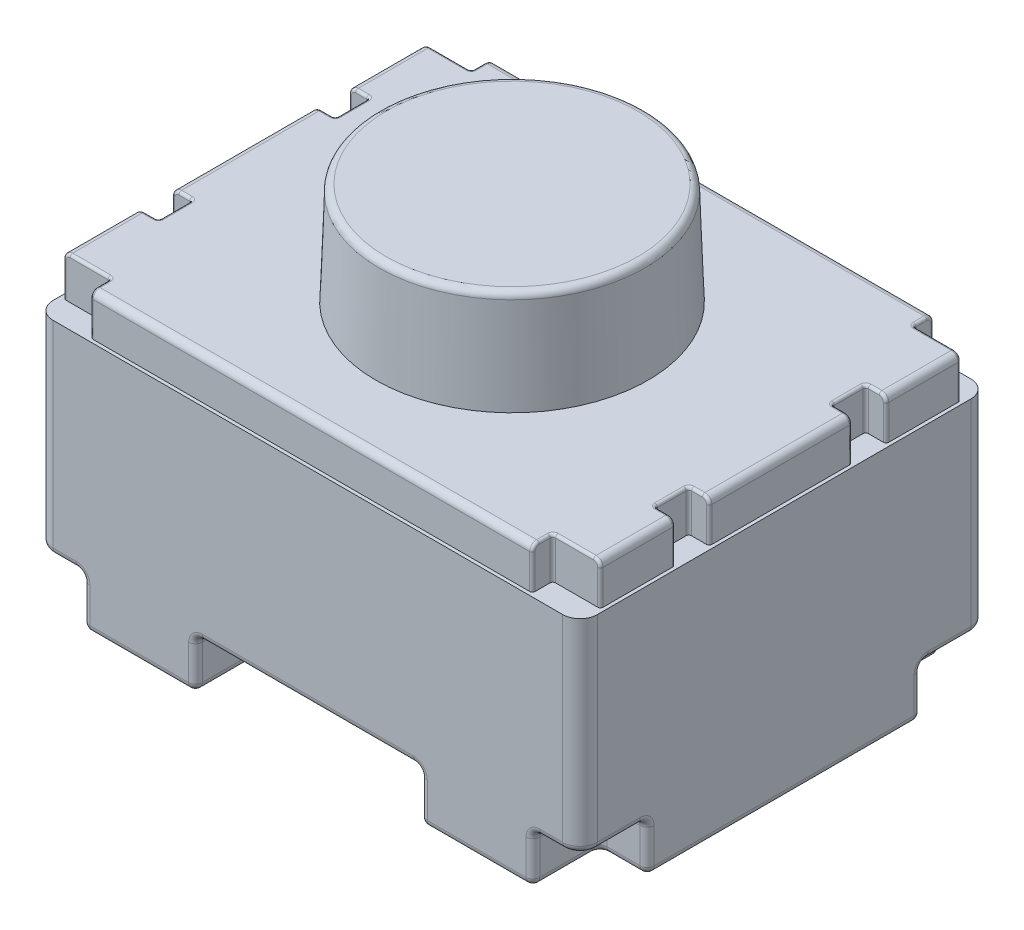
from build123d import *

# Parameters (mm, degrees)
BOSS_EXTRUDE1_START = 0.5588
SKETCH1_W           = 4
SKETCH1_H           = 3
BOSS_EXTRUDE1_DEPTH = 1.5
FILLET1_R           = 0.127
BOSS_EXTRUDE2_DEPTH = 0.3048
BOSS_EXTRUDE3_REACH = 4.564
BOSS_EXTRUDE3_START = 0.2
SKETCH5_R           = 1
BOSS_EXTRUDE5_DEPTH = 0.75
BOSS_EXTRUDE5_TAPER = 2
FILLET3_R           = 0.0508
SKETCH6_W           = 0.15
SKETCH6_H           = 0.25
CUT_EXTRUDE1_DEPTH  = 0.3048
FILLET4_R           = 0.02
FILLET5_R           = 0.05


with BuildPart() as part:
    # Sketch1 → Boss-Extrude1 (new body)
    with BuildSketch(Plane(origin=(0, 0, 0), x_dir=(1, 0, 0), z_dir=(0, 1, 0)).offset(BOSS_EXTRUDE1_START)):
        Rectangle(SKETCH1_W, SKETCH1_H)
    extrude(amount=BOSS_EXTRUDE1_DEPTH)

    # Fillet1
    fillet1_edges = [part.edges().sort_by_distance(p)[0] for p in [
        (2, 1.3088, 1.5),
        (-2, 1.3088, 1.5),
        (-2, 1.3088, -1.5),
        (2, 1.3088, -1.5),
    ]]
    fillet(fillet1_edges, radius=FILLET1_R)

    # Sketch2 → Boss-Extrude2 (add)
    with BuildSketch(Plane(origin=(0, 2.0588, 0), x_dir=(-1, 0, 0), z_dir=(0, -1, 0))):
        with BuildLine():
            Line((1.9746, -1.373), (1.9746, 1.373))
            ThreePointArc((1.9746, 1.373), (1.944842049, 1.444842049), (1.873, 1.4746))
            Line((1.873, 1.4746), (-1.873, 1.4746))
            ThreePointArc((-1.873, 1.4746), (-1.944842049, 1.444842049), (-1.9746, 1.373))
            Line((-1.9746, 1.373), (-1.9746, -1.373))
            ThreePointArc((-1.9746, -1.373), (-1.944842049, -1.444842049), (-1.873, -1.4746))
            Line((-1.873, -1.4746), (1.873, -1.4746))
            ThreePointArc((1.873, -1.4746), (1.944842049, -1.444842049), (1.9746, -1.373))
        make_face()
    extrude(amount=-BOSS_EXTRUDE2_DEPTH)

    # Sketch3 → Boss-Extrude3 (add, up to next)
    with BuildSketch(Plane(origin=(0, 0, 0), x_dir=(1, 0, 0), z_dir=(0, 1, 0)).offset(BOSS_EXTRUDE3_START), mode=Mode.PRIVATE) as boss_extrude3_sk1:
        Polygon((-1.65323541, -1.5), (-1.65323541, -1.006902093), (-2, -1.006902093), (-2, 1.006902093), (-1.65323541, 1.006902093), (-1.65323541, 1.5), (-0.826439501, 1.5), (-0.826439501, 0.473804959), (-1.582835796, 0.473804959), (-1.582835796, -0.473804959), (-0.826439501, -0.473804959), (-0.826439501, -1.5), align=None)
    boss_extrude3_tool1 = extrude(boss_extrude3_sk1.sketch, amount=BOSS_EXTRUDE3_REACH, mode=Mode.PRIVATE) - part.part
    add(boss_extrude3_tool1.solids().sort_by_distance((-1.621022, 0.2, 1.253451))[0])
    # Sketch3 → Boss-Extrude3 (add, up to next)
    with BuildSketch(Plane(origin=(0, 0, 0), x_dir=(1, 0, 0), z_dir=(0, 1, 0)).offset(BOSS_EXTRUDE3_START), mode=Mode.PRIVATE) as boss_extrude3_sk2:
        Polygon((1.65323541, 1.5), (1.65323541, 1.006902093), (2, 1.006902093), (2, -1.006902093), (1.65323541, -1.006902093), (1.65323541, -1.5), (0.826439501, -1.5), (0.826439501, -0.473804959), (1.582835796, -0.473804959), (1.582835796, 0.473804959), (0.826439501, 0.473804959), (0.826439501, 1.5), align=None)
    boss_extrude3_tool2 = extrude(boss_extrude3_sk2.sketch, amount=BOSS_EXTRUDE3_REACH, mode=Mode.PRIVATE) - part.part
    add(boss_extrude3_tool2.solids().sort_by_distance((1.621022, 0.2, -1.253451))[0])

    # Sketch5 → Boss-Extrude5 (add)
    with BuildSketch(Plane(origin=(0, 2.3636, 0), x_dir=(1, 0, 0), z_dir=(0, 1, 0))):
        Circle(SKETCH5_R)
    extrude(amount=BOSS_EXTRUDE5_DEPTH, taper=BOSS_EXTRUDE5_TAPER)

    # Fillet3
    fillet3_edges = [part.edges().sort_by_distance(p)[0] for p in [
        (0.826439501, 0.5588, -0.98690248),
        (0.826439501, 0.3794, -1.5),
        (0.826439501, 0.2, -0.98690248),
        (1.204637649, 0.5588, -0.473804959),
        (0.826439501, 0.3794, -0.473804959),
        (1.204637649, 0.2, -0.473804959),
        (1.582835796, 0.5588, 0),
        (1.582835796, 0.3794, -0.473804959),
        (1.582835796, 0.2, 0),
        (1.204637649, 0.5588, 0.473804959),
        (1.582835796, 0.3794, 0.473804959),
        (1.204637649, 0.2, 0.473804959),
        (0.826439501, 0.5588, 0.98690248),
        (0.826439501, 0.3794, 0.473804959),
        (0.826439501, 0.2, 0.98690248),
        (0.826439501, 0.3794, 1.5),
        (1.239837456, 0.2, 1.5),
        (1.65323541, 0.5588, 1.253451047),
        (1.65323541, 0.3794, 1.5),
        (1.65323541, 0.2, 1.253451047),
        (1.826617705, 0.5588, 1.006902093),
        (1.65323541, 0.3794, 1.006902093),
        (1.826617705, 0.2, 1.006902093),
        (2, 0.3794, 1.006902093),
        (2, 0.2, 0),
        (1.826617705, 0.5588, -1.006902093),
        (2, 0.3794, -1.006902093),
        (1.826617705, 0.2, -1.006902093),
        (1.65323541, 0.3794, -1.5),
        (1.239837456, 0.2, -1.5),
        (1.65323541, 0.5588, -1.253451047),
        (1.65323541, 0.3794, -1.006902093),
        (1.65323541, 0.2, -1.253451047),
        (-1.763117705, 0.5588, 1.5),
        (2, 0.5588, 1.189951047),
        (-2, 0.5588, -1.189951047),
        (1.763117705, 0.5588, -1.5),
        (1.962802561, 0.5588, 1.462802561),
        (1.962802561, 0.5588, -1.462802561),
        (-1.962802561, 0.5588, -1.462802561),
        (-1.962802561, 0.5588, 1.462802561),
        (-1.944842049, 2.3636, 1.444842049),
        (0, 2.3636, 1.4746),
        (1.944842049, 2.3636, 1.444842049),
        (1.9746, 2.3636, 0),
        (1.944842049, 2.3636, -1.444842049),
        (0, 2.3636, -1.4746),
        (-1.944842049, 2.3636, -1.444842049),
        (-1.9746, 2.3636, 0),
        (0, 0.5588, 1.5),
        (-2, 0.5588, 1.189951047),
        (-1.763117705, 0.5588, -1.5),
        (-0.826439501, 0.5588, 0.98690248),
        (-0.826439501, 0.3794, 1.5),
        (-0.826439501, 0.2, 0.98690248),
        (-1.204637649, 0.5588, 0.473804959),
        (-0.826439501, 0.3794, 0.473804959),
        (-1.204637649, 0.2, 0.473804959),
        (-1.582835796, 0.5588, 0),
        (-1.582835796, 0.3794, 0.473804959),
        (-1.582835796, 0.2, 0),
        (-1.204637649, 0.5588, -0.473804959),
        (-1.582835796, 0.3794, -0.473804959),
        (-1.204637649, 0.2, -0.473804959),
        (-0.826439501, 0.5588, -0.98690248),
        (-0.826439501, 0.3794, -0.473804959),
        (-0.826439501, 0.2, -0.98690248),
        (-0.826439501, 0.3794, -1.5),
        (-1.239837456, 0.2, -1.5),
        (-1.65323541, 0.5588, -1.253451047),
        (-1.65323541, 0.3794, -1.5),
        (-1.65323541, 0.2, -1.253451047),
        (-1.826617705, 0.5588, -1.006902093),
        (-1.65323541, 0.3794, -1.006902093),
        (-1.826617705, 0.2, -1.006902093),
        (-2, 0.3794, -1.006902093),
        (-2, 0.2, 0),
        (-1.826617705, 0.5588, 1.006902093),
        (-2, 0.3794, 1.006902093),
        (-1.826617705, 0.2, 1.006902093),
        (-1.65323541, 0.3794, 1.5),
        (-1.239837456, 0.2, 1.5),
        (-1.65323541, 0.5588, 1.253451047),
        (-1.65323541, 0.3794, 1.006902093),
        (-1.65323541, 0.2, 1.253451047),
        (0, 0.5588, -1.5),
        (2, 0.5588, -1.189951047),
        (1.763117705, 0.5588, 1.5),
    ]]
    fillet(fillet3_edges, radius=FILLET3_R)

    # Sketch6 → Cut-Extrude1 (cut)
    with BuildSketch(Plane(origin=(0, 2.3636, 0), x_dir=(1, 0, 0), z_dir=(0, 1, 0))):
        with Locations((-1.8996, 0.65)):
            Rectangle(SKETCH6_W, SKETCH6_H)
        with BuildLine():
            Line((-1.6246, 1.3246), (-1.9746, 1.3246))
            Line((-1.9746, 1.3246), (-1.9746, 1.373))
            ThreePointArc((-1.9746, 1.373), (-1.944842049, 1.444842049), (-1.873, 1.4746))
            Line((-1.873, 1.4746), (-1.6246, 1.4746))
            Line((-1.6246, 1.4746), (-1.6246, 1.3246))
        make_face()
        with BuildLine():
            Line((1.9746, 1.3246), (1.9746, 1.373))
            ThreePointArc((1.9746, 1.373), (1.944842049, 1.444842049), (1.873, 1.4746))
            Line((1.873, 1.4746), (1.6246, 1.4746))
            Line((1.6246, 1.4746), (1.6246, 1.3246))
            Line((1.6246, 1.3246), (1.9746, 1.3246))
        make_face()
        with Locations((1.8996, 0.65)):
            Rectangle(SKETCH6_W, SKETCH6_H)
        with Locations((1.8996, -0.65)):
            Rectangle(SKETCH6_W, SKETCH6_H)
        with BuildLine():
            Line((1.6246, -1.3246), (1.9746, -1.3246))
            Line((1.9746, -1.3246), (1.9746, -1.373))
            ThreePointArc((1.9746, -1.373), (1.944842049, -1.444842049), (1.873, -1.4746))
            Line((1.873, -1.4746), (1.6246, -1.4746))
            Line((1.6246, -1.4746), (1.6246, -1.3246))
        make_face()
        with BuildLine():
            Line((-1.9746, -1.3246), (-1.9746, -1.373))
            ThreePointArc((-1.9746, -1.373), (-1.944842049, -1.444842049), (-1.873, -1.4746))
            Line((-1.873, -1.4746), (-1.6246, -1.4746))
            Line((-1.6246, -1.4746), (-1.6246, -1.3246))
            Line((-1.6246, -1.3246), (-1.9746, -1.3246))
        make_face()
        with Locations((-1.8996, -0.65)):
            Rectangle(SKETCH6_W, SKETCH6_H)
    extrude(amount=-CUT_EXTRUDE1_DEPTH, mode=Mode.SUBTRACT)

    # Fillet4
    fillet4_edges = [part.edges().sort_by_distance(p)[0] for p in [
        (-1.6246, 2.2112, 1.3246),
        (-1.6246, 2.1858, 1.4746),
        (-1.6246, 2.348721024, 1.459721024),
        (-1.6246, 2.3636, 1.3742),
        (-1.7742, 2.3636, 1.3246),
        (-1.959721024, 2.348721024, 1.3246),
        (-1.9746, 2.1858, 1.3246),
        (-1.9746, 2.1858, 0.525),
        (-1.959721024, 2.348721024, 0.525),
        (-1.8742, 2.3636, 0.525),
        (-1.8246, 2.2112, 0.525),
        (-1.8246, 2.3636, 0.65),
        (-1.8246, 2.2112, 0.775),
        (-1.8742, 2.3636, 0.775),
        (-1.959721024, 2.348721024, 0.775),
        (-1.9746, 2.1858, 0.775),
        (-1.9746, 2.1858, -0.525),
        (-1.959721024, 2.348721024, -0.525),
        (-1.8742, 2.3636, -0.525),
        (-1.8246, 2.2112, -0.525),
        (-1.8246, 2.3636, -0.65),
        (-1.8246, 2.2112, -0.775),
        (-1.8742, 2.3636, -0.775),
        (-1.959721024, 2.348721024, -0.775),
        (-1.9746, 2.1858, -0.775),
        (-1.9746, 2.1858, -1.3246),
        (-1.959721024, 2.348721024, -1.3246),
        (-1.7742, 2.3636, -1.3246),
        (-1.6246, 2.2112, -1.3246),
        (-1.6246, 2.3636, -1.3742),
        (-1.6246, 2.348721024, -1.459721024),
        (-1.6246, 2.1858, -1.4746),
        (1.6246, 2.1858, -1.4746),
        (1.6246, 2.348721024, -1.459721024),
        (1.6246, 2.3636, -1.3742),
        (1.9746, 2.1858, -1.3246),
        (1.959721024, 2.348721024, -1.3246),
        (1.7742, 2.3636, -1.3246),
        (1.6246, 2.2112, -1.3246),
        (1.8246, 2.2112, -0.775),
        (1.9746, 2.1858, -0.775),
        (1.959721024, 2.348721024, -0.775),
        (1.8742, 2.3636, -0.775),
        (1.8246, 2.3636, -0.65),
        (1.9746, 2.1858, -0.525),
        (1.8742, 2.3636, -0.525),
        (1.959721024, 2.348721024, -0.525),
        (1.8246, 2.2112, -0.525),
        (1.9746, 2.1858, 0.525),
        (1.8742, 2.3636, 0.525),
        (1.959721024, 2.348721024, 0.525),
        (1.8246, 2.2112, 0.525),
        (1.8246, 2.3636, 0.65),
        (1.9746, 2.1858, 1.3246),
        (1.6246, 2.1858, 1.4746),
        (1.959721024, 2.348721024, 0.775),
        (1.8742, 2.3636, 0.775),
        (1.8246, 2.2112, 0.775),
        (1.9746, 2.1858, 0.775),
        (1.6246, 2.2112, 1.3246),
        (1.6246, 2.3636, 1.3742),
        (1.7742, 2.3636, 1.3246),
    ]]
    fillet(fillet4_edges, radius=FILLET4_R)

    # Fillet5
    fillet5_edges = [part.edges().sort_by_distance(p)[0] for p in [
        (-0.973809423, 3.1136, 0),
    ]]
    fillet(fillet5_edges, radius=FILLET5_R)


solid = part.part
